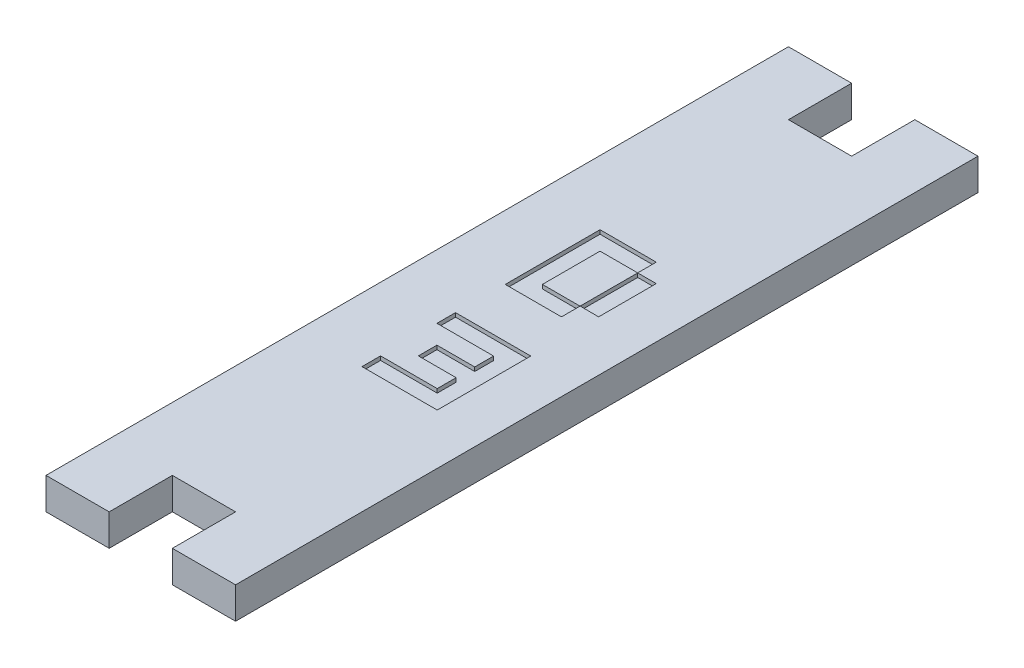
from build123d import *

# Parameters (mm, degrees)
SKETCH_1_W          = 24
SKETCH_1_H          = 94
EXTRUDE_1_DEPTH     = 4
SKETCH_2_W          = 8
SKETCH_2_H          = 8
CUT_EXTRUDE_1_DEPTH = 5
SKETCH_3_W          = 8
SKETCH_3_H          = 8
CUT_EXTRUDE_2_DEPTH = 5
CUT_EXTRUDE_3_DEPTH = 0.5
CUT_EXTRUDE_4_DEPTH = 0.5
CUT_EXTRUDE_5_DEPTH = 0.5


with BuildPart() as part:
    # 草圖1 → 填料-伸長1 (new body)
    with BuildSketch(Plane(origin=(0, 4, 0), x_dir=(1, 0, 0), z_dir=(0, 1, 0))):
        Rectangle(SKETCH_1_W, SKETCH_1_H)
    extrude(amount=-EXTRUDE_1_DEPTH)

    # 草圖2 → 除料-伸長1 (cut, through all)
    with BuildSketch(Plane.XZ):
        with Locations((0, -43)):
            Rectangle(SKETCH_2_W, SKETCH_2_H)
    extrude(amount=-CUT_EXTRUDE_1_DEPTH, mode=Mode.SUBTRACT)

    # 草圖3 → 除料-伸長2 (cut, through all)
    with BuildSketch(Plane.XZ):
        with Locations((0, 43)):
            Rectangle(SKETCH_3_W, SKETCH_3_H)
    extrude(amount=-CUT_EXTRUDE_2_DEPTH, mode=Mode.SUBTRACT)

    # 草圖4 → 除料-伸長3 (cut)
    with BuildSketch(Plane(origin=(0, 4, 0), x_dir=(-1, 0, 0), z_dir=(0, 1, 0))):
        Polygon((-5.604611564, 15.070843631), (-5.604611564, 3.228998522), (3.921964275, 3.228998522), (3.921964275, 5.581554951), (-3.252055136, 5.581554951), (-3.252055136, 7.973642862), (1.530624471, 7.973642862), (1.530624471, 10.326199291), (-3.252055136, 10.326199291), (-3.252055136, 12.718289616), (3.921964275, 12.718289616), (3.921964275, 15.070843631), align=None)
    extrude(amount=-CUT_EXTRUDE_3_DEPTH, mode=Mode.SUBTRACT)

    # 草圖5 → 除料-伸長4 (cut)
    with BuildSketch(Plane(origin=(0, 4, 0), x_dir=(-1, 0, 0), z_dir=(0, 1, 0))):
        Polygon((1.512356153, -5.362438696), (1.512356153, -12.657328252), (-3.252055136, -12.657328252), (-3.252055136, -15.009884681), (3.864912581, -15.009884681), (3.864912581, -3.009884681), (-3.252055136, -3.009884681), (-3.252055136, -5.362438696), align=None)
    extrude(amount=-CUT_EXTRUDE_4_DEPTH, mode=Mode.SUBTRACT)

    # 草圖6 → 除料-伸長5 (cut)
    with BuildSketch(Plane(origin=(0, 4, 0), x_dir=(-1, 0, 0), z_dir=(0, 1, 0))):
        Polygon((-5.604611564, -12.657328252), (-3.262055136, -12.657328252), (-3.252055136, -5.372438696), (-5.604611564, -5.362438696), align=None)
    extrude(amount=-CUT_EXTRUDE_5_DEPTH, mode=Mode.SUBTRACT)


solid = part.part
